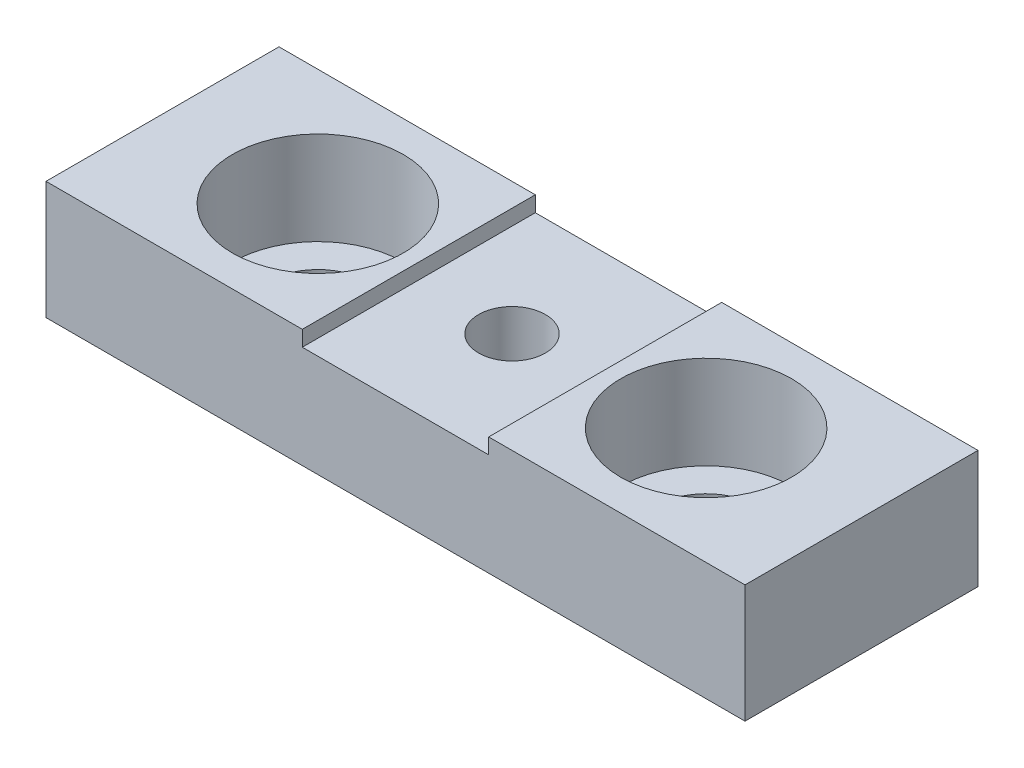
from build123d import *

# Parameters (mm, degrees)
SKETCH1_W                      = 45
SKETCH1_H                      = 15
SKETCH1_R                      = 2.15
BOSS_EXTRUDE1_DEPTH            = 7.6
CBORE_FOR_M6_SHCS1_D           = 6.6
CBORE_FOR_M6_SHCS1_CBORE_D     = 11
CBORE_FOR_M6_SHCS1_CBORE_DEPTH = 6
SKETCH5_W                      = 12
SKETCH5_H                      = 15
CUT_EXTRUDE2_DEPTH             = 1


with BuildPart() as part:
    # Sketch1 → Boss-Extrude1 (new body)
    with BuildSketch(Plane(origin=(0, 0, 0), x_dir=(1, 0, 0), z_dir=(0, 1, 0))):
        Rectangle(SKETCH1_W, SKETCH1_H)
        Circle(SKETCH1_R, mode=Mode.SUBTRACT)
    extrude(amount=BOSS_EXTRUDE1_DEPTH)

    # CBORE for M6 SHCS1 (through all)
    with Locations(Plane(origin=(0, 7.6, 0), x_dir=(1, 0, 0), z_dir=(0, 1, 0))):
        with Locations((-12.5, 0), (12.5, 0)):
            CounterBoreHole(CBORE_FOR_M6_SHCS1_D / 2, CBORE_FOR_M6_SHCS1_CBORE_D / 2, CBORE_FOR_M6_SHCS1_CBORE_DEPTH)

    # Sketch5 → Cut-Extrude2 (cut)
    with BuildSketch(Plane(origin=(0, 7.6, 0), x_dir=(1, 0, 0), z_dir=(0, 1, 0))):
        Rectangle(SKETCH5_W, SKETCH5_H)
    extrude(amount=-CUT_EXTRUDE2_DEPTH, mode=Mode.SUBTRACT)


solid = part.part
